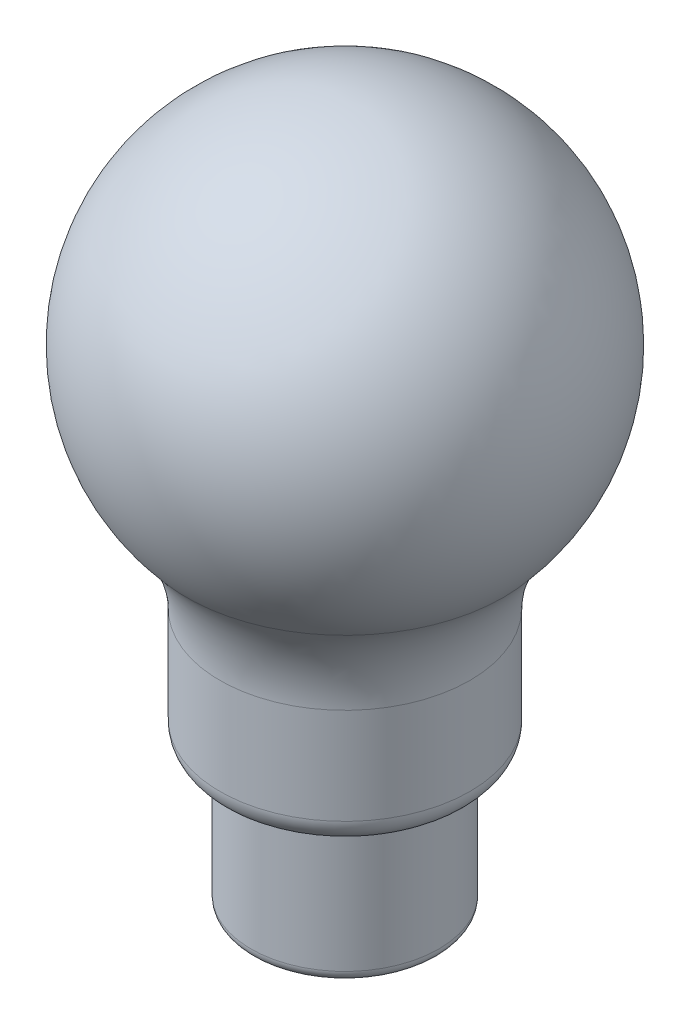
from build123d import *

# Parameters (mm, degrees)
SKETCH1_R               = 0.5
SKETCH3_R               = 0.5
SKETCH5_R               = 0.125
CUT_EXTRUDE1_DEPTH      = 9.833579848
CUT_EXTRUDE1_DEPTH_BACK = 9.499722439


with BuildPart() as part:
    # Sweep1: sweep along a path in Sketch2
    with BuildLine(Plane.XY) as sweep1_path:
        add(Edge.make_bspline(
            [(7.5, 0), (7.069674779, 25.011273871), (8.334728021, 50)],
            knots=[0, 0, 0, 1, 1, 1], degree=2))
    # Sketch1 → Sweep1 (sweep)
    with BuildSketch(Plane(origin=(0, 0, 0), x_dir=(1, 0, 0), z_dir=(0, 1, 0))):
        with Locations((7.5, 0)):
            Circle(SKETCH1_R)
    sweep(path=sweep1_path.line)


with BuildPart() as body_2:
    # Sweep2: sweep along a path in Sketch4
    with BuildLine(Plane.XY) as sweep2_path:
        add(Edge.make_bspline(
            [(-7.5, 0), (-7.333356477, 25.003471788), (-8, 50)],
            knots=[0, 0, 0, 1, 1, 1], degree=2))
    # Sketch3 → Sweep2 (sweep)
    with BuildSketch(Plane(origin=(0, 0, 0), x_dir=(1, 0, 0), z_dir=(0, 1, 0))):
        with Locations((-7.5, 0)):
            Circle(SKETCH3_R)
    sweep(path=sweep2_path.line)


with BuildPart() as cut_extrude1_tool:
    # Sketch5 → Cut-Extrude1 (new body, two sides)
    with BuildSketch(Plane(origin=(0, 0, 0), x_dir=(0, 0, -1), z_dir=(1, 0, 0))) as cut_extrude1_sk:
        with Locations((0.074023712, 49)):
            Circle(SKETCH5_R)
    extrude(amount=CUT_EXTRUDE1_DEPTH)
    extrude(cut_extrude1_sk.sketch, amount=-CUT_EXTRUDE1_DEPTH_BACK)


with BuildPart() as part_1:
    add(part.part)

    # Cut-Extrude1: cut by cut_extrude1_tool
    add(cut_extrude1_tool.part, mode=Mode.SUBTRACT)


with BuildPart() as body_2_1:
    add(body_2.part)

    # Cut-Extrude1: cut by cut_extrude1_tool
    add(cut_extrude1_tool.part, mode=Mode.SUBTRACT)


with BuildPart() as body_3:
    # Sketch6 → Revolve2 (revolve)
    with BuildSketch(Plane.XY):
        with BuildLine():
            Line((0, 90.6), (0, 90))
            ThreePointArc((0, 90), (-27.343134833, 72.343134833), (-22.5, 40.156865167))
            ThreePointArc((-22.5, 40.156865167), (-18.791713066, 33.999176424), (-17.5, 26.928108612))
            Line((-17.5, 26.928108612), (-17.5, 13))
            ThreePointArc((-17.5, 13), (-16.621320344, 10.878679656), (-14.5, 10))
            Line((-14.5, 10), (-14, 10))
            ThreePointArc((-14, 10), (-13.292893219, 9.707106781), (-13, 9))
            Line((-13, 9), (-13, -9))
            ThreePointArc((-13, -9), (-12.707106781, -9.707106781), (-12, -10))
            Line((-12, -10), (-12, -10.6))
            ThreePointArc((-12, -10.6), (-13.13137085, -10.13137085), (-13.6, -9))
            Line((-13.6, -9), (-13.6, 9))
            ThreePointArc((-13.6, 9), (-13.717157288, 9.282842712), (-14, 9.4))
            Line((-14, 9.4), (-14.5, 9.4))
            ThreePointArc((-14.5, 9.4), (-17.045584412, 10.454415588), (-18.1, 13))
            Line((-18.1, 13), (-18.1, 26.928108612))
            ThreePointArc((-18.1, 26.928108612), (-19.352961674, 33.787044389), (-22.95, 39.76000247))
            ThreePointArc((-22.95, 39.76000247), (-27.88999753, 72.58999753), (0, 90.6))
        make_face()
    revolve(axis=Axis((0, -10.6, 0), (0, 1, 0)))


solid = Compound([part_1.part, body_2_1.part, body_3.part])
